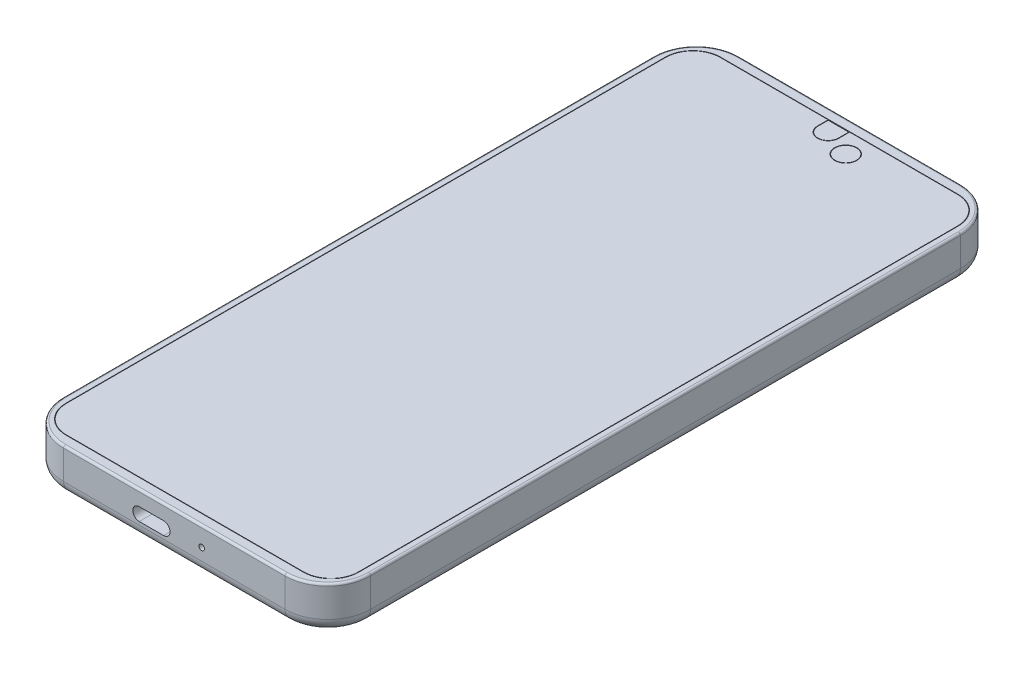
from build123d import *

# Parameters (mm, degrees)
SKIZZE1_W                            = 71.8
SKIZZE1_H                            = 158
AUFSATZ_LINEAR_AUSTRAGEN1_DEPTH      = 10.25
VERRUNDUNG1_R                        = 10
VERRUNDUNG2_R                        = 3
VERRUNDUNG3_R                        = 0.5
SCHNITT_LINEAR_AUSTRAGEN_D_NN1_DEPTH = 0.5
SCHNITT_LINEAR_AUSTRAGEN_D_NN2_DEPTH = 0.5
SKIZZE4_R                            = 2.6
SKIZZE4_R_2                          = 2.5
SCHNITT_LINEAR_AUSTRAGEN_D_NN3_DEPTH = 0.5
AUFSATZ_LINEAR_AUSTRAGEN2_DEPTH      = 0.5
SKIZZE6_R                            = 1.875
SKIZZE6_R_2                          = 0.65
SCHNITT_LINEAR_AUSTRAGEN1_DEPTH      = 25
SKIZZE7_R                            = 0.65
SCHNITT_LINEAR_AUSTRAGEN2_DEPTH      = 7
SKIZZE8_R                            = 5.25
SCHNITT_LINEAR_AUSTRAGEN3_DEPTH      = 0.9
FASE1_SIZE                           = 0.8
SCHNITT_LINEAR_AUSTRAGEN4_DEPTH      = 0.3
FASE2_SIZE                           = 0.2


with BuildPart() as part:
    # Skizze1 → Aufsatz-Linear austragen1 (new body)
    with BuildSketch(Plane(origin=(0, 0, 0), x_dir=(1, 0, 0), z_dir=(0, 1, 0))):
        Rectangle(SKIZZE1_W, SKIZZE1_H)
    extrude(amount=AUFSATZ_LINEAR_AUSTRAGEN1_DEPTH)

    # Verrundung1
    verrundung1_edges = [part.edges().sort_by_distance(p)[0] for p in [
        (35.9, 5.125, 79),
        (-35.9, 5.125, 79),
        (-35.9, 5.125, -79),
        (35.9, 5.125, -79),
    ]]
    fillet(verrundung1_edges, radius=VERRUNDUNG1_R)

    # Verrundung2
    verrundung2_edges = [part.edges().sort_by_distance(p)[0] for p in [
        (-35.9, 0, 0),
        (35.9, 0, 0),
        (0, 0, 79),
        (0, 0, -79),
        (32.971067812, 0, 76.071067812),
        (-32.971067812, 0, 76.071067812),
        (32.971067812, 0, -76.071067812),
        (-32.971067812, 0, -76.071067812),
    ]]
    fillet(verrundung2_edges, radius=VERRUNDUNG2_R)

    # Verrundung3
    verrundung3_edges = [part.edges().sort_by_distance(p)[0] for p in [
        (-35.9, 10.25, 0),
        (0, 10.25, -79),
        (35.9, 10.25, 0),
        (0, 10.25, 79),
        (32.971067812, 10.25, 76.071067812),
        (-32.971067812, 10.25, 76.071067812),
        (32.971067812, 10.25, -76.071067812),
        (-32.971067812, 10.25, -76.071067812),
    ]]
    fillet(verrundung3_edges, radius=VERRUNDUNG3_R)

    # Skizze2 → Schnitt-Linear-Austragen-Dünn1 (cut)
    with BuildSketch(Plane(origin=(0, 10.25, 0), x_dir=(1, 0, 0), z_dir=(0, 1, 0))):
        with BuildLine():
            Line((-27.75, 76.575), (27.75, 76.575))
            ThreePointArc((27.75, 76.575), (32.346194078, 74.671194078), (34.25, 70.075))
            Line((34.25, 70.075), (34.25, -70.075))
            ThreePointArc((34.25, -70.075), (32.346194078, -74.671194078), (27.75, -76.575))
            Line((27.75, -76.575), (-27.75, -76.575))
            ThreePointArc((-27.75, -76.575), (-32.346194078, -74.671194078), (-34.25, -70.075))
            Line((-34.25, -70.075), (-34.25, 70.075))
            ThreePointArc((-34.25, 70.075), (-32.346194078, 74.671194078), (-27.75, 76.575))
        make_face()
        with BuildLine():
            Line((-27.75, 76.475), (27.75, 76.475))
            ThreePointArc((27.75, 76.475), (32.2754834, 74.6004834), (34.15, 70.075))
            Line((34.15, 70.075), (34.15, -70.075))
            ThreePointArc((34.15, -70.075), (32.2754834, -74.6004834), (27.75, -76.475))
            Line((27.75, -76.475), (-27.75, -76.475))
            ThreePointArc((-27.75, -76.475), (-32.2754834, -74.6004834), (-34.15, -70.075))
            Line((-34.15, -70.075), (-34.15, 70.075))
            ThreePointArc((-34.15, 70.075), (-32.2754834, 74.6004834), (-27.75, 76.475))
        make_face(mode=Mode.SUBTRACT)
    extrude(amount=-SCHNITT_LINEAR_AUSTRAGEN_D_NN1_DEPTH, mode=Mode.SUBTRACT)

    # Skizze3 → Schnitt-Linear-Austragen-Dünn2 (cut)
    with BuildSketch(Plane(origin=(0, 10.25, 0), x_dir=(1, 0, 0), z_dir=(0, 1, 0))):
        with BuildLine():
            Line((-0.01, 71.475), (0.01, 71.475))
            ThreePointArc((0.01, 71.475), (1.770695885, 72.204304115), (2.5, 73.965))
            Line((2.5, 73.965), (2.5, 76.475))
            Line((2.5, 76.475), (-2.5, 76.475))
            Line((-2.5, 76.475), (-2.5, 73.965))
            ThreePointArc((-2.5, 73.965), (-1.770695885, 72.204304115), (-0.01, 71.475))
        make_face()
        with BuildLine():
            Line((-0.01, 71.575), (0.01, 71.575))
            ThreePointArc((0.01, 71.575), (1.699985207, 72.275014793), (2.4, 73.965))
            Line((2.4, 73.965), (2.4, 76.375))
            Line((2.4, 76.375), (-2.4, 76.375))
            Line((-2.4, 76.375), (-2.4, 73.965))
            ThreePointArc((-2.4, 73.965), (-1.699985207, 72.275014793), (-0.01, 71.575))
        make_face(mode=Mode.SUBTRACT)
    extrude(amount=-SCHNITT_LINEAR_AUSTRAGEN_D_NN2_DEPTH, mode=Mode.SUBTRACT)

    # Skizze4 → Schnitt-Linear-Austragen-Dünn3 (cut)
    with BuildSketch(Plane(origin=(0, 10.25, 0), x_dir=(1, 0, 0), z_dir=(0, 1, 0))):
        with Locations((6.5, 71.575)):
            Circle(SKIZZE4_R)
        with Locations((6.5, 71.575)):
            Circle(SKIZZE4_R_2, mode=Mode.SUBTRACT)
    extrude(amount=-SCHNITT_LINEAR_AUSTRAGEN_D_NN3_DEPTH, mode=Mode.SUBTRACT)

    # Skizze5 → Aufsatz-Linear austragen2 (add)
    with BuildSketch(Plane.ZY.offset(35.9)):
        with BuildLine():
            Line((-45.7, 4.61), (-36.1, 4.61))
            Line((-36.1, 4.61), (-36.1, 7.25))
            Line((-36.1, 7.25), (-45.7, 7.25))
            ThreePointArc((-45.7, 7.25), (-46.619238816, 6.869238816), (-47, 5.95))
            Line((-47, 5.95), (-47, 5.91))
            ThreePointArc((-47, 5.91), (-46.619238816, 4.990761184), (-45.7, 4.61))
        make_face()
        with BuildLine():
            Line((-24.2, 7.25), (-33.8, 7.25))
            Line((-33.8, 7.25), (-33.8, 4.61))
            Line((-33.8, 4.61), (-24.2, 4.61))
            ThreePointArc((-24.2, 4.61), (-23.280761184, 4.990761184), (-22.9, 5.91))
            Line((-22.9, 5.91), (-22.9, 5.95))
            ThreePointArc((-22.9, 5.95), (-23.280761184, 6.869238816), (-24.2, 7.25))
        make_face()
        with BuildLine():
            Line((-5.5, 7.25), (-13.95, 7.25))
            ThreePointArc((-13.95, 7.25), (-14.869238816, 6.869238816), (-15.25, 5.95))
            Line((-15.25, 5.95), (-15.25, 5.91))
            ThreePointArc((-15.25, 5.91), (-14.869238816, 4.990761184), (-13.95, 4.61))
            Line((-13.95, 4.61), (-5.5, 4.61))
            ThreePointArc((-5.5, 4.61), (-4.580761184, 4.990761184), (-4.2, 5.91))
            Line((-4.2, 5.91), (-4.2, 5.95))
            ThreePointArc((-4.2, 5.95), (-4.580761184, 6.869238816), (-5.5, 7.25))
        make_face()
    extrude(amount=AUFSATZ_LINEAR_AUSTRAGEN2_DEPTH)

    # Skizze6 → Schnitt-Linear austragen1 (cut)
    with BuildSketch(Plane(origin=(0, 0, -79), x_dir=(-1, 0, 0), z_dir=(0, 0, -1))):
        with Locations((23.4, 4.55)):
            Circle(SKIZZE6_R)
        with Locations((12.4, 6)):
            Circle(SKIZZE6_R_2)
    extrude(amount=-SCHNITT_LINEAR_AUSTRAGEN1_DEPTH, mode=Mode.SUBTRACT)

    # Skizze7 → Schnitt-Linear austragen2 (cut)
    with BuildSketch(Plane.XY.offset(79)):
        with Locations((6.4, 5.8)):
            Circle(SKIZZE7_R)
        with BuildLine():
            Line((-8.2, 6.75), (-2.5, 6.75))
            ThreePointArc((-2.5, 6.75), (-1, 5.25), (-2.5, 3.75))
            Line((-2.5, 3.75), (-8.2, 3.75))
            ThreePointArc((-8.2, 3.75), (-9.7, 5.25), (-8.2, 6.75))
        make_face()
    extrude(amount=-SCHNITT_LINEAR_AUSTRAGEN2_DEPTH, mode=Mode.SUBTRACT)

    # Skizze8 → Schnitt-Linear austragen3 (cut)
    with BuildSketch(Plane.XZ):
        with Locations((0, -55.5)):
            Circle(SKIZZE8_R)
    extrude(amount=-SCHNITT_LINEAR_AUSTRAGEN3_DEPTH, mode=Mode.SUBTRACT)

    # Fase1
    fase1_edges = [part.edges().sort_by_distance(p)[0] for p in [
        (-5.25, 0, -55.5),
    ]]
    chamfer(fase1_edges, length=FASE1_SIZE)

    # Skizze9 → Schnitt-Linear austragen4 (cut)
    with BuildSketch(Plane.XZ):
        with BuildLine():
            Line((25.4, -74.5), (16.5, -74.5))
            ThreePointArc((16.5, -74.5), (11, -69), (16.5, -63.5))
            Line((16.5, -63.5), (25.4, -63.5))
            ThreePointArc((25.4, -63.5), (30.9, -69), (25.4, -74.5))
        make_face()
    extrude(amount=-SCHNITT_LINEAR_AUSTRAGEN4_DEPTH, mode=Mode.SUBTRACT)

    # Fase2
    fase2_edges = [part.edges().sort_by_distance(p)[0] for p in [
        (30.9, 0, -69),
        (20.95, 0, -63.5),
        (11, 0, -69),
        (20.95, 0, -74.5),
    ]]
    chamfer(fase2_edges, length=FASE2_SIZE)


solid = part.part
